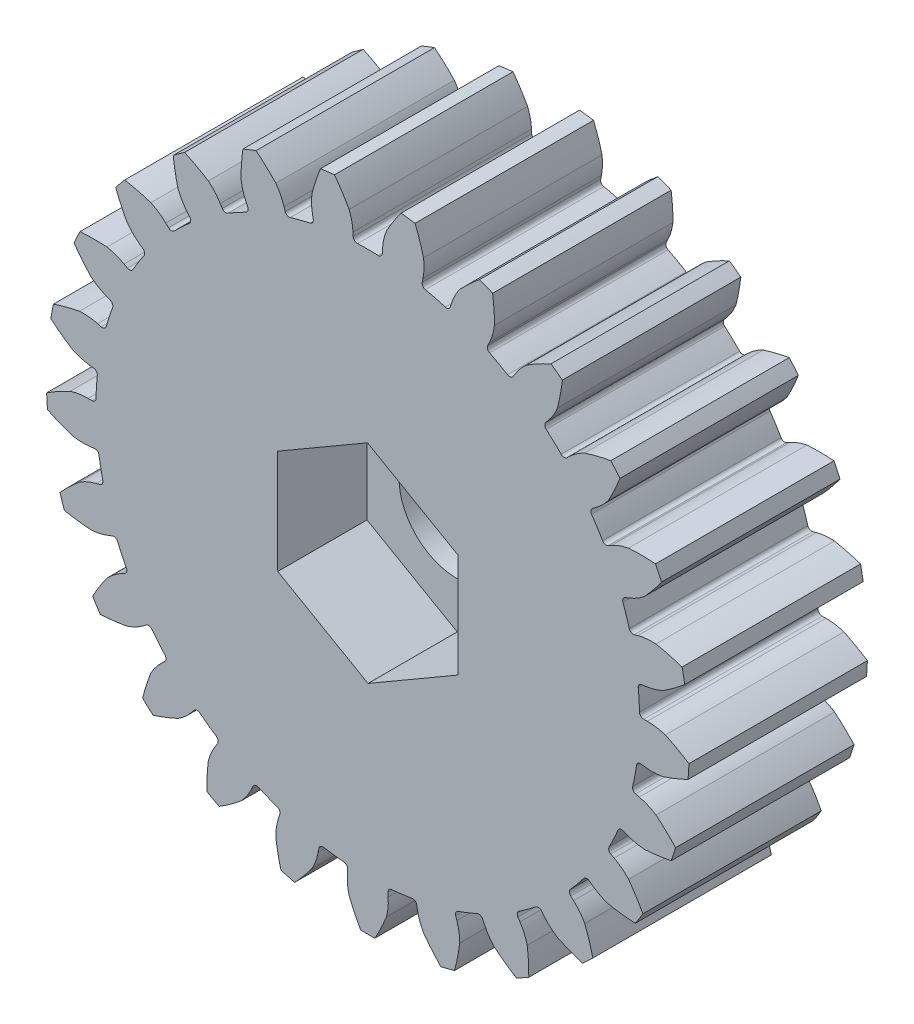
from build123d import *

# Parameters (mm, degrees)
ESBO_O1_R                = 7.140000001
RESSALTO_EXTRUS_O1_DEPTH = 5
ESBO_O1_3_R              = 18.009000001
RESSALTO_EXTRUS_O2_DEPTH = 10
ESBO_O2_R                = 3.250000001
CORTE_EXTRUS_O1_DEPTH    = 16
CORTE_EXTRUS_O2_DEPTH    = 10
PADR_OCIRCULAR1_COUNT    = 25
CORTE_EXTRUS_O3_DEPTH    = 5


with BuildPart() as part:
    # Esboço1 → Ressalto-extrusão1 (new body)
    with BuildSketch(Plane.XY.offset(-10.203659164)):
        with Locations((175.260000179, -1.578e-06)):
            Circle(ESBO_O1_R)
    extrude(amount=-RESSALTO_EXTRUS_O1_DEPTH)

    # Esboço1<3> → Ressalto-extrusão2 (add)
    with BuildSketch(Plane.XY.offset(-10.203659164)):
        with Locations((175.260000179, -1.578e-06)):
            Circle(ESBO_O1_3_R)
    extrude(amount=RESSALTO_EXTRUS_O2_DEPTH)

    # Esboço2 → Corte-extrusão1 (cut, through all)
    with BuildSketch(Plane.XY.offset(-0.203659164)):
        with Locations((175.260000179, -1.578e-06)):
            Circle(ESBO_O2_R)
    extrude(amount=-CORTE_EXTRUS_O1_DEPTH, mode=Mode.SUBTRACT)

    # Esboço3 → Corte-extrusão2 (cut)
    with BuildSketch(Plane.XY.offset(-0.203659164)):
        with BuildLine():
            Line((176.07415523, 15.43733342), (176.085252565, 15.647751896))
            ThreePointArc((176.085252565, 15.647751896), (176.15406513, 16.15406015), (176.305000179, 16.642221832))
            ThreePointArc((176.305000179, 16.642221832), (176.693052085, 17.290772935), (177.122939455, 17.912383475))
            ThreePointArc((177.122939455, 17.912383475), (175.260000179, 18.008997775), (173.397060904, 17.912383475))
            ThreePointArc((173.397060904, 17.912383475), (173.826948274, 17.290772935), (174.215000179, 16.642221832))
            ThreePointArc((174.215000179, 16.642221832), (174.365935228, 16.15406015), (174.434747794, 15.647751896))
            Line((174.434747794, 15.647751896), (174.445845128, 15.43733342))
            ThreePointArc((174.445845128, 15.43733342), (174.520414877, 15.279621545), (174.68422093, 15.21961105))
            ThreePointArc((174.68422093, 15.21961105), (175.260000179, 15.230498423), (175.835779428, 15.21961105))
            ThreePointArc((175.835779428, 15.21961105), (175.999585482, 15.279621545), (176.07415523, 15.43733342))
        make_face()
    corte_extrus_o2 = extrude(amount=-CORTE_EXTRUS_O2_DEPTH, mode=Mode.SUBTRACT)

    # PadrãoCircular1: Corte-extrusão2 ×25 about axis
    padr_ocircular1_axis = Axis((175.260000179, -1.578e-06, 0), (0, 0, 1))
    for i in range(1, PADR_OCIRCULAR1_COUNT):
        add(corte_extrus_o2.rotate(padr_ocircular1_axis, i * 360 / PADR_OCIRCULAR1_COUNT), mode=Mode.SUBTRACT)

    # Esboço4 → Corte-extrusão3 (cut)
    with BuildSketch(Plane.XY.offset(-0.203659164)):
        Polygon((175.246708941, 5.831220994), (170.203367678, 2.904099158), (170.216658917, -2.927123414), (175.273291418, -5.831224149), (180.31663268, -2.904102313), (180.303341442, 2.927120258), align=None)
    extrude(amount=-CORTE_EXTRUS_O3_DEPTH, mode=Mode.SUBTRACT)


solid = part.part
